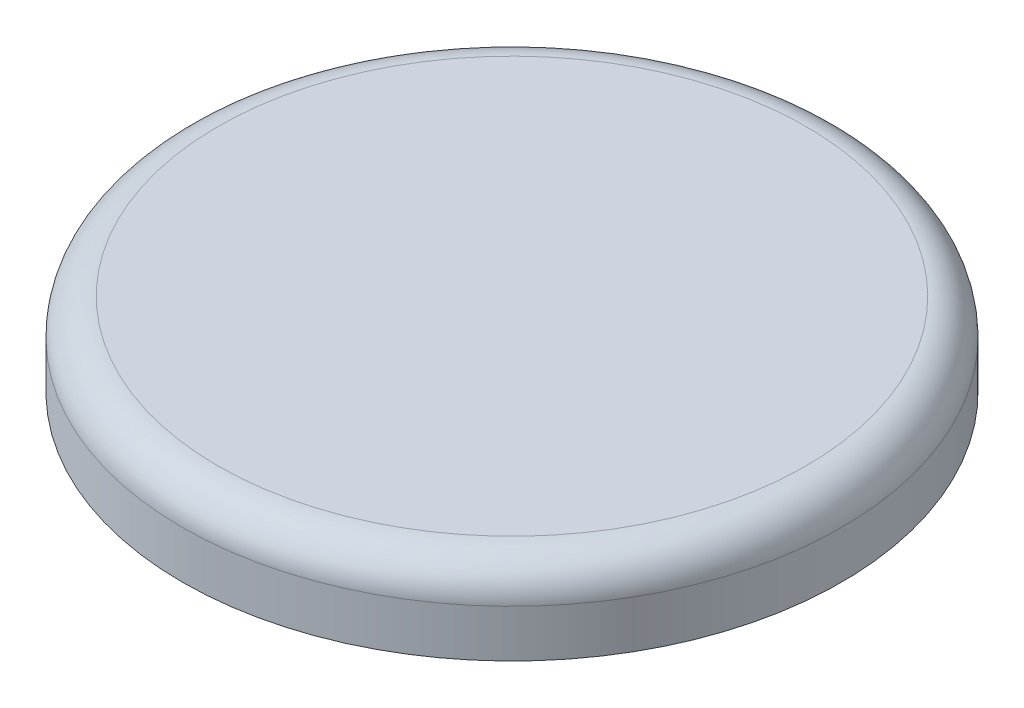
from build123d import *

# Parameters (mm, degrees)
SKETCH1_R           = 27.81
BOSS_EXTRUDE1_DEPTH = 7
FILLET1_R           = 3
SHELL6_T            = -2
SKETCH6_R           = 2.5
BOSS_EXTRUDE5_DEPTH = 7
SKETCH9_R           = 1.75
SKETCH9_W           = 1.5
SKETCH9_H           = 9.824978118
CUT_EXTRUDE1_DEPTH  = 7
CUT_EXTRUDE2_DEPTH  = 7
CUT_EXTRUDE3_START  = -7
SKETCH12_R          = 1.75
SKETCH12_W          = 1.5
SKETCH12_H          = 13.411449206
SKETCH12_W_2        = 11.847320856
SKETCH12_H_2        = 1.5
CUT_EXTRUDE3_DEPTH  = 7


with BuildPart() as part:
    # Sketch1 → Boss-Extrude1 (new body)
    with BuildSketch(Plane(origin=(0, 0, 0), x_dir=(1, 0, 0), z_dir=(0, 1, 0))):
        with Locations(Location((0, 0, 0), (0, 0, 270))):
            Circle(SKETCH1_R)
    extrude(amount=BOSS_EXTRUDE1_DEPTH)

    # Fillet1
    fillet1_edges = [part.edges().sort_by_distance(p)[0] for p in [
        (0, 7, -27.81),
    ]]
    fillet(fillet1_edges, radius=FILLET1_R)

    # Shell6
    shell6_openings = [part.faces().sort_by_distance(p)[0] for p in [
        (0, 0, 0),
    ]]
    offset(amount=SHELL6_T, openings=shell6_openings, kind=Kind.INTERSECTION)

    # Sketch6 → Boss-Extrude5 (add)
    with BuildSketch(Plane.XZ.offset(-5)):
        with Locations(Location((9.817188382, 0, 0), (0, 0, 90))):
            Circle(SKETCH6_R)
        with Locations(Location((-9.82, 0, 0), (0, 0, 90))):
            Circle(SKETCH6_R)
    extrude(amount=BOSS_EXTRUDE5_DEPTH)

    # Sketch9 → Cut-Extrude1 (cut)
    with BuildSketch(Plane.XZ.offset(2)):
        with Locations((-9.82, 0)):
            Circle(SKETCH9_R)
        with Locations((-9.82, 0)):
            Rectangle(SKETCH9_W, SKETCH9_H)
    extrude(amount=-CUT_EXTRUDE1_DEPTH, mode=Mode.SUBTRACT)

    # Sketch10 → Cut-Extrude2 (cut)
    with BuildSketch(Plane.XZ.offset(2)):
        with BuildLine():
            Line((9.067188382, 4.571331513), (9.067188382, 2.384848004))
            ThreePointArc((9.067188382, 2.384848004), (9.817188382, 2.5), (10.567188382, 2.384848004))
            Line((10.567188382, 2.384848004), (10.567188382, 4.571331513))
            Line((10.567188382, 4.571331513), (9.067188382, 4.571331513))
        make_face()
        with BuildLine():
            ThreePointArc((9.067188382, -2.384848004), (9.817188382, -2.5), (10.567188382, -2.384848004))
            Line((10.567188382, -2.384848004), (10.567188382, -1.58113883))
            ThreePointArc((10.567188382, -1.58113883), (9.817188382, -1.75), (9.067188382, -1.58113883))
            Line((9.067188382, -1.58113883), (9.067188382, -2.384848004))
        make_face()
        with BuildLine():
            ThreePointArc((10.567188382, 2.384848004), (9.817188382, 2.5), (9.067188382, 2.384848004))
            Line((9.067188382, 2.384848004), (9.067188382, 1.58113883))
            ThreePointArc((9.067188382, 1.58113883), (9.817188382, 1.75), (10.567188382, 1.58113883))
            Line((10.567188382, 1.58113883), (10.567188382, 2.384848004))
        make_face()
        with BuildLine():
            ThreePointArc((9.067188382, -1.58113883), (9.817188382, -1.75), (10.567188382, -1.58113883))
            Line((10.567188382, -1.58113883), (10.567188382, 1.58113883))
            ThreePointArc((10.567188382, 1.58113883), (9.817188382, 1.75), (9.067188382, 1.58113883))
            Line((9.067188382, 1.58113883), (9.067188382, -1.58113883))
        make_face()
        with BuildLine():
            Line((9.067188382, -4.571331513), (10.567188382, -4.571331513))
            Line((10.567188382, -4.571331513), (10.567188382, -2.384848004))
            ThreePointArc((10.567188382, -2.384848004), (9.817188382, -2.5), (9.067188382, -2.384848004))
            Line((9.067188382, -2.384848004), (9.067188382, -4.571331513))
        make_face()
        with BuildLine():
            Line((10.567188382, 1.58113883), (10.567188382, -1.58113883))
            ThreePointArc((10.567188382, -1.58113883), (11.296208328, -0.935414347), (11.567188382, 0))
            ThreePointArc((11.567188382, 0), (11.296208328, 0.935414347), (10.567188382, 1.58113883))
        make_face()
        with BuildLine():
            ThreePointArc((9.067188382, 1.58113883), (8.067188382, 0), (9.067188382, -1.58113883))
            Line((9.067188382, -1.58113883), (9.067188382, 1.58113883))
        make_face()
    extrude(amount=-CUT_EXTRUDE2_DEPTH, mode=Mode.SUBTRACT)


with BuildPart() as body_2:
    # Sketch4 → Revolve1 (revolve)
    with BuildSketch(Plane.XY, mode=Mode.PRIVATE) as revolve1_sk:
        Polygon((3.65, 7), (3.65, 3.6), (4.6, 3.6), (2.5, 0), (1.5, 0), (1.5, 7), align=None)
    revolve(revolve1_sk.sketch.rotate(Axis((0, 7.379912855, 0), (0, -1, 0)), 270), axis=Axis((0, 7.379912855, 0), (0, -1, 0)))


with BuildPart() as body_2_1:
    # Body-Move/Copy1: moved
    add(body_2.part.moved(Location((0, -2, 0))))

    # Sketch12 → Cut-Extrude3 (cut)
    with BuildSketch(Plane.XZ.offset(2).offset(CUT_EXTRUDE3_START)):
        Circle(SKETCH12_R)
        Rectangle(SKETCH12_W, SKETCH12_H)
        Rectangle(SKETCH12_W_2, SKETCH12_H_2)
    extrude(amount=CUT_EXTRUDE3_DEPTH, mode=Mode.SUBTRACT)


with BuildPart() as cut_extrude3_piece_1:
    # of the separate pieces the step leaves, piece 1, a body of its own (cut_extrude3_pieces)
    add(body_2_1.part.solids().sort_by_distance((3.57211422, 5, 0.75))[0])


with BuildPart() as cut_extrude3_piece_2:
    # of the separate pieces the step leaves, piece 2, a body of its own (cut_extrude3_pieces)
    add(body_2_1.part.solids().sort_by_distance((-3.57211422, 5, 0.75))[0])


with BuildPart() as cut_extrude3_piece_3:
    # of the separate pieces the step leaves, piece 3, a body of its own (cut_extrude3_pieces)
    add(body_2_1.part.solids().sort_by_distance((0.75, 5, -3.57211422))[0])


with BuildPart() as cut_extrude3_piece_4:
    # of the separate pieces the step leaves, piece 4, a body of its own (cut_extrude3_pieces)
    add(body_2_1.part.solids().sort_by_distance((-3.57211422, 5, -0.75))[0])


solid = Compound([part.part, cut_extrude3_piece_1.part, cut_extrude3_piece_2.part, cut_extrude3_piece_3.part, cut_extrude3_piece_4.part])
